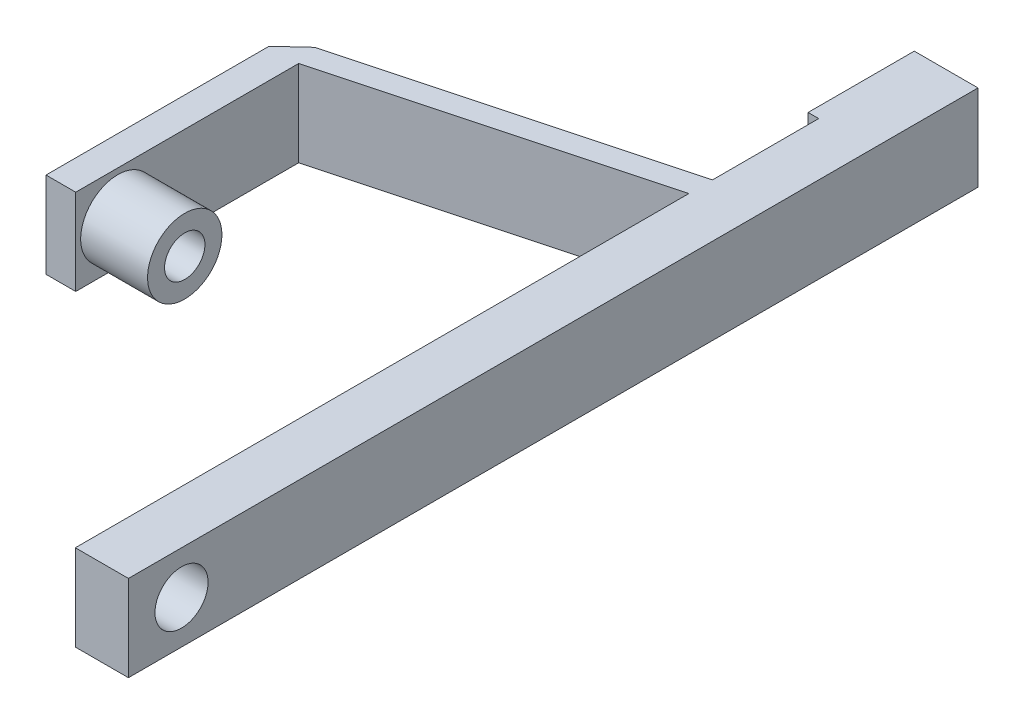
from build123d import *

# Parameters (mm, degrees)
SKETCH1_W         = 12.7
SKETCH1_H         = 177.8
EXTRUSION1_DEPTH  = 20.574
EXTRUSION3_DEPTH  = 20.32
SKETCH4_R         = 6.35
EXTRUSION4_DEPTH  = 20.32
EXTRUSION5_DEPTH  = 0.254
SKETCH7_R         = 6.0071
EXTRUSION7_DEPTH  = 0.508
SKETCH8_R         = 4.826
EXTRUSION8_DEPTH  = 22.86
SKETCH9_R         = 8.89
SKETCH9_R_2       = 6.0071
EXTRUSION9_DEPTH  = 16.002
SKETCH10_R        = 6.0071
SKETCH10_R_2      = 4.826
EXTRUSION10_DEPTH = 16.002
SKETCH11_W        = 12.7
SKETCH11_H        = 20.574
EXTRUSION14_DEPTH = 25.4
SKETCH12_W        = 25.4
SKETCH12_H        = 20.574
EXTRUSION15_DEPTH = 2.54


with BuildPart() as part:
    # Sketch1 → Extrusion1 (new body)
    with BuildSketch(Plane(origin=(0, 0, 0), x_dir=(-1, 0, 0), z_dir=(0, 1, 0))):
        with Locations((6.35, -88.9)):
            Rectangle(SKETCH1_W, SKETCH1_H)
    extrude(amount=EXTRUSION1_DEPTH)

    # Sketch3 → Extrusion3 (add)
    with BuildSketch(Plane.XZ):
        Polygon((-12.7, -152.4), (-12.7, -146.7612), (-86.303547963, -127.039188763), (-86.303547963, -73.699188763), (-93.415547963, -73.699188763), (-93.415547963, -127.039188763), (-87.713247963, -132.300260787), align=None)
    extrude(amount=-EXTRUSION3_DEPTH)

    # Sketch4 → Extrusion4 (cut)
    with BuildSketch(Plane.ZY.offset(12.7)):
        with Locations((-12.7, 10.287)):
            Circle(SKETCH4_R)
    extrude(amount=-EXTRUSION4_DEPTH, mode=Mode.SUBTRACT)

    # Sketch5 → Extrusion5 (add)
    with BuildSketch(Plane(origin=(0, 20.32, 0), x_dir=(1, 0, 0), z_dir=(0, 1, 0))):
        Polygon((-86.303547963, 73.699188763), (-86.303547963, 127.039188763), (-12.7, 146.7612), (-12.7, 152.4), (-87.713247963, 132.300260787), (-93.415547963, 127.039188763), (-93.415547963, 73.699188763), align=None)
    extrude(amount=EXTRUSION5_DEPTH)

    # Sketch7 → Extrusion7 (cut)
    with BuildSketch(Plane.ZY.offset(93.415547963)):
        with Locations((-83.770288763, 10.287)):
            Circle(SKETCH7_R)
    extrude(amount=-EXTRUSION7_DEPTH, mode=Mode.SUBTRACT)

    # Sketch8 → Extrusion8 (cut)
    with BuildSketch(Plane.ZY.offset(92.907547963)):
        with Locations((-83.770288763, 10.287)):
            Circle(SKETCH8_R)
    extrude(amount=-EXTRUSION8_DEPTH, mode=Mode.SUBTRACT)

    # Sketch9 → Extrusion9 (add)
    with BuildSketch(Plane(origin=(-86.303547963, 0, 0), x_dir=(0, 0, -1), z_dir=(1, 0, 0))):
        with Locations((83.770288763, 10.287)):
            Circle(SKETCH9_R)
        with Locations((83.770288763, 10.287)):
            Circle(SKETCH9_R_2, mode=Mode.SUBTRACT)
    extrude(amount=EXTRUSION9_DEPTH)

    # Sketch10 → Extrusion10 (add)
    with BuildSketch(Plane(origin=(-86.303547963, 10.287, -83.770288763), x_dir=(0, 0, -1), z_dir=(1, 0, 0))):
        Circle(SKETCH10_R)
        Circle(SKETCH10_R_2, mode=Mode.SUBTRACT)
    extrude(amount=EXTRUSION10_DEPTH)

    # Sketch11 → Extrusion14 (add)
    with BuildSketch(Plane(origin=(0, 0, -177.8), x_dir=(-1, 0, 0), z_dir=(0, 0, -1))):
        with Locations((6.35, 10.287)):
            Rectangle(SKETCH11_W, SKETCH11_H)
    extrude(amount=EXTRUSION14_DEPTH)

    # Sketch12 → Extrusion15 (add)
    with BuildSketch(Plane.ZY.offset(12.7)):
        with Locations((-190.5, 10.287)):
            Rectangle(SKETCH12_W, SKETCH12_H)
    extrude(amount=EXTRUSION15_DEPTH)


solid = part.part
